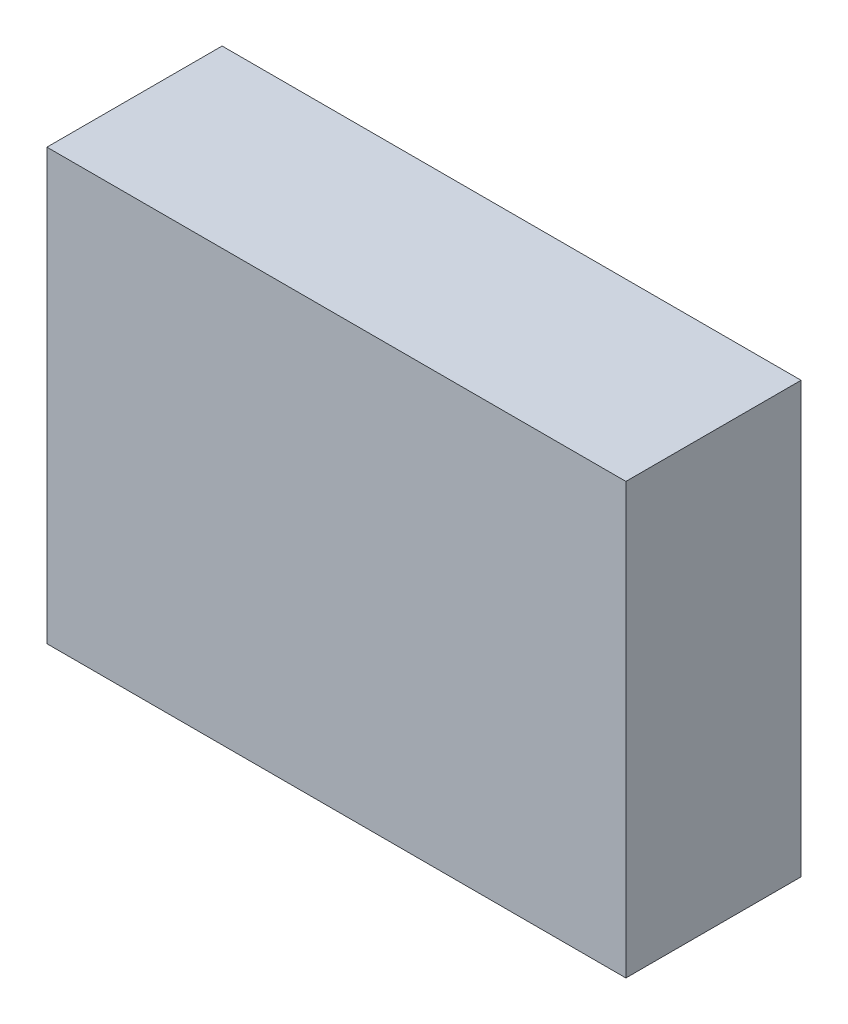
from build123d import *

# Parameters (mm, degrees)
ESQUISSE1_W        = 132.2
ESQUISSE1_H        = 98.2
BOSS_EXTRU_1_DEPTH = 40


with BuildPart() as part:
    # Esquisse1 → Boss.-Extru.1 (new body)
    with BuildSketch(Plane.XY):
        Rectangle(ESQUISSE1_W, ESQUISSE1_H)
    extrude(amount=BOSS_EXTRU_1_DEPTH)


solid = part.part
